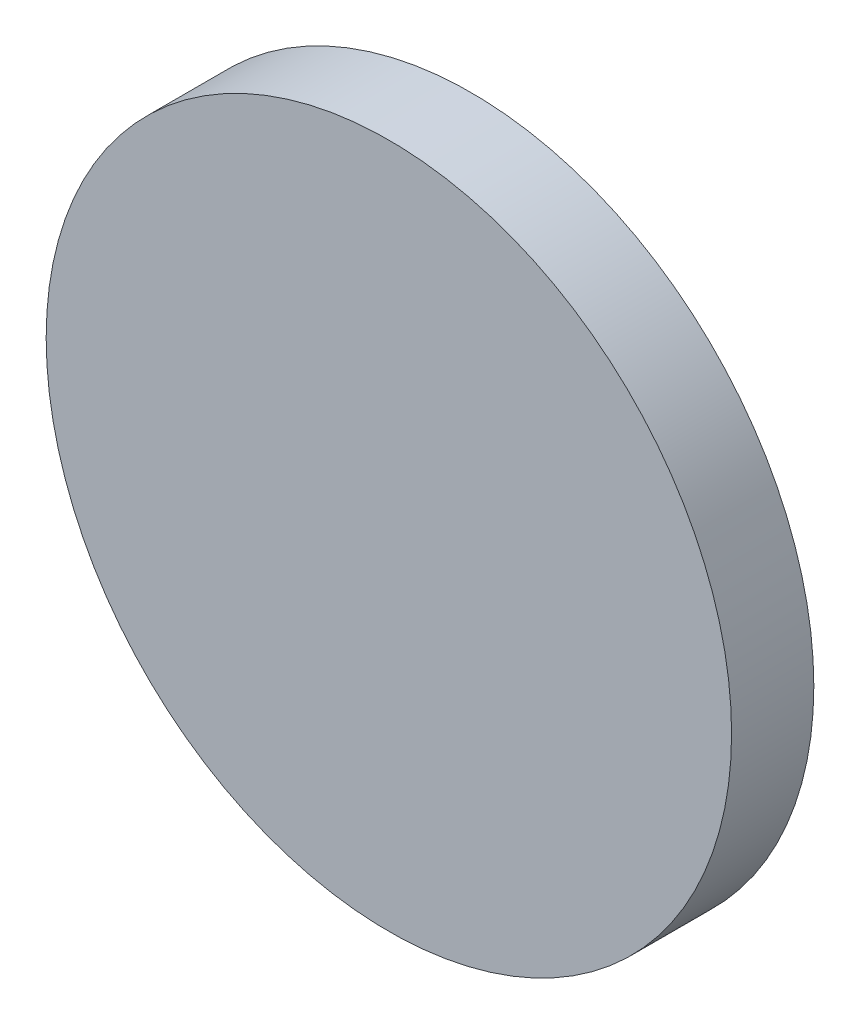
from build123d import *

# Parameters (mm, degrees)
SKETCH_1_R      = 12.5
EXTRUDE_1_DEPTH = 3


with BuildPart() as part:
    # 草图1 → 凸台-拉伸1 (new body)
    with BuildSketch(Plane.XY):
        Circle(SKETCH_1_R)
    extrude(amount=EXTRUDE_1_DEPTH)


solid = part.part
